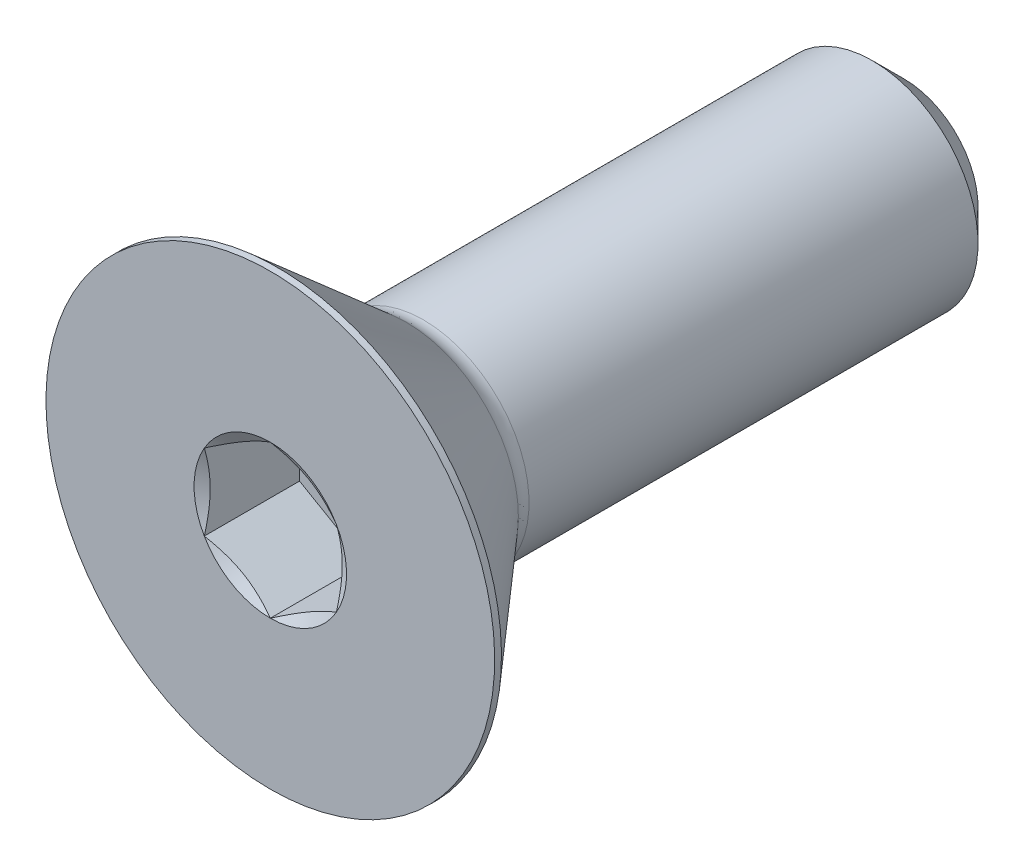
from build123d import *

# Parameters (mm, degrees)
SKETCH1_W          = 19.05
SKETCH1_H          = 3.175
CHAMFER1_SIZE      = 0.9525
CUT_EXTRUDE2_DEPTH = 2.86258


with BuildPart() as part:
    # Sketch1 → Revolve1 (revolve)
    with BuildSketch(Plane(origin=(0, 0, 0), x_dir=(0, 0, -1), z_dir=(1, 0, 0))):
        with Locations((9.525, 1.5875)):
            Rectangle(SKETCH1_W, SKETCH1_H)
    revolve(axis=Axis((0, 0, -19.05), (0, 0, 1)))

    # Chamfer1
    chamfer1_edges = [part.edges().sort_by_distance(p)[0] for p in [
        (0, -3.175, -19.05),
    ]]
    chamfer(chamfer1_edges, length=CHAMFER1_SIZE)

    # Sketch7 → Revolve2 (revolve)
    with BuildSketch(Plane(origin=(0, 0, 0), x_dir=(0, 0, -1), z_dir=(1, 0, 0)), mode=Mode.PRIVATE) as revolve2_sk:
        with BuildLine():
            Line((0, 6.7437), (0.20447, 6.7437))
            Line((0.20447, 6.7437), (4.0894, 3.366581874))
            ThreePointArc((4.0894, 3.366581874), (4.328282675, 3.224461616), (4.601808997, 3.175))
            Line((4.601808997, 3.175), (4.601808997, 0))
            Line((4.601808997, 0), (0, 0))
            Line((0, 0), (0, 6.7437))
        make_face()
    revolve(revolve2_sk.sketch.rotate(Axis((0, 0, 0), (0, 0, -1)), 180), axis=Axis((0, 0, 0), (0, 0, -1)))

    # Boss-Extrude1 cone 1 section (through the dimple's axis) → Boss-Extrude1 (revolve)
    with BuildSketch(Plane(origin=(0, 0, -4.601808997), x_dir=(0, -1, 0), z_dir=(1, 0, 0))):
        Polygon((0, 0), (3.175, 0), (0, 3.06606186), align=None)
    revolve(axis=Axis((0, 0, -4.601808997), (0, 0, -1)))

    # Sketch5 → Cut-Extrude2 (cut)
    with BuildSketch(Plane.XY):
        Polygon((0, 2.291358881), (-1.984375, 1.14567944), (-1.984375, -1.14567944), (0, -2.291358881), (1.984375, -1.14567944), (1.984375, 1.14567944), align=None)
    extrude(amount=-CUT_EXTRUDE2_DEPTH, mode=Mode.SUBTRACT)

    # Cut-Extrude3 cone 1 section (through the dimple's axis) → Cut-Extrude3 (revolve, cut)
    with BuildSketch(Plane(origin=(0, 0, 0), x_dir=(0, -1, 0), z_dir=(1, 0, 0))):
        Polygon((0, 0), (2.291358881, 0), (0, 1.322916667), align=None)
    revolve(axis=Axis((0, 0, 0), (0, 0, -1)), mode=Mode.SUBTRACT)


solid = part.part
